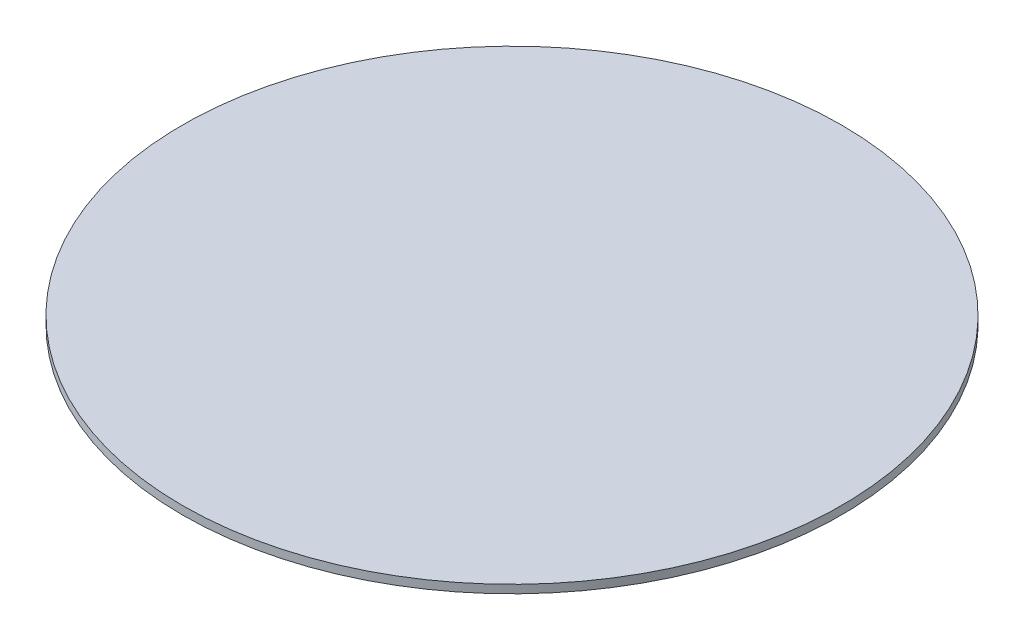
from build123d import *

# Parameters (mm, degrees)
SKETCH1_R           = 15.875
BOSS_EXTRUDE1_DEPTH = 0.396875


with BuildPart() as part:
    # Sketch1 → Boss-Extrude1 (new body)
    with BuildSketch(Plane(origin=(0, 0, 0), x_dir=(1, 0, 0), z_dir=(0, 1, 0))):
        Circle(SKETCH1_R)
    extrude(amount=BOSS_EXTRUDE1_DEPTH)


solid = part.part
